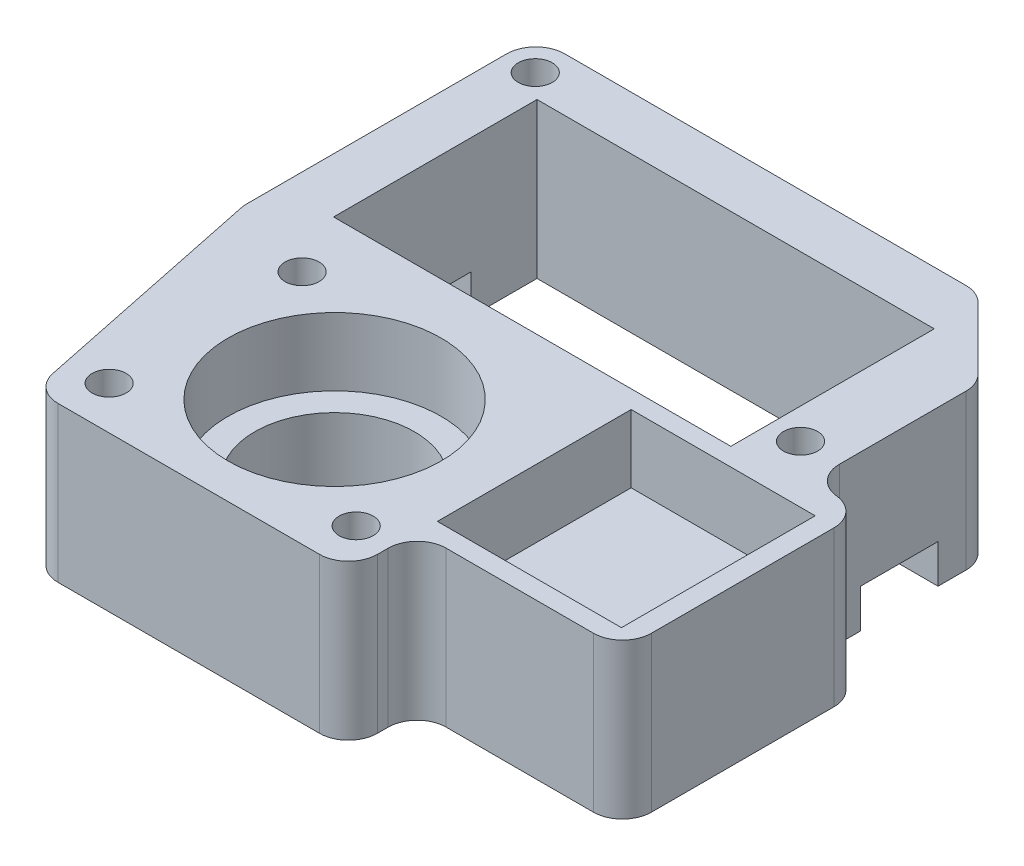
from build123d import *

# Parameters (mm, degrees)
ESBO_O1_R                = 8.25
ESBO_O1_R_2              = 1.759398981
ESBO_O1_W                = 41
ESBO_O1_H                = 21
RESSALTO_EXTRUS_O1_DEPTH = 16
ESBO_O2_R                = 11
ESBO_O2_W                = 19
ESBO_O2_H                = 20
CORTE_EXTRUS_O1_DEPTH    = 7
FILETE2_R                = 3
FILETE3_R                = 3
ESBO_O4_W                = 8
ESBO_O4_H                = 4
CORTE_EXTRUS_O2_DEPTH    = 60


with BuildPart() as part:
    # Esboço1 → Ressalto-extrusão1 (new body)
    with BuildSketch(Plane(origin=(0, 0, 0), x_dir=(1, 0, 0), z_dir=(0, 1, 0))):
        Polygon((-30, -1.447454982), (-30, 28.699395637), (15.649759457, 28.699395637), (23.854058099, 20.495096994), (23.854058099, 3.185553214), (29.26109124, 3.185553214), (29.26109124, -21.609914281), (8.073270411, -21.609914281), (8.073270411, -28.699395637), (-24.350240543, -28.699395637), align=None)
        with Locations((-7.979986437, -14.080173672)):
            Circle(ESBO_O1_R, mode=Mode.SUBTRACT)
        with Locations((-26.846540224, 25.498704653)):
            Circle(ESBO_O1_R_2, mode=Mode.SUBTRACT)
        with Locations((19.799323859, 6.233376584)):
            Circle(ESBO_O1_R_2, mode=Mode.SUBTRACT)
        with Locations((-21.074944534, -24.259345494)):
            Circle(ESBO_O1_R_2, mode=Mode.SUBTRACT)
        with Locations((4.428183177, -24.259345494)):
            Circle(ESBO_O1_R_2, mode=Mode.SUBTRACT)
        with Locations((-21.074944534, -4.342364945)):
            Circle(ESBO_O1_R_2, mode=Mode.SUBTRACT)
        with Locations((-3.850240543, 12.685553214)):
            Rectangle(ESBO_O1_W, ESBO_O1_H, mode=Mode.SUBTRACT)
    extrude(amount=RESSALTO_EXTRUS_O1_DEPTH)

    # Esboço2 → Corte-extrusão1 (cut)
    with BuildSketch(Plane(origin=(0, 16, 0), x_dir=(1, 0, 0), z_dir=(0, 1, 0))):
        with Locations((-7.979986437, -14.080173672)):
            Circle(ESBO_O2_R)
        with Locations((17.716848977, -9.668999278)):
            Rectangle(ESBO_O2_W, ESBO_O2_H)
    extrude(amount=-CORTE_EXTRUS_O1_DEPTH, mode=Mode.SUBTRACT)

    # Filete2
    filete2_edges = [part.edges().sort_by_distance(p)[0] for p in [
        (-30, 8, 1.447454982),
        (-30, 8, -28.699395637),
        (15.649759457, 8, -28.699395637),
        (23.854058099, 8, -20.495096994),
        (23.854058099, 8, -3.185553214),
        (8.073270411, 8, 28.699395637),
        (-24.350240543, 8, 28.699395637),
    ]]
    fillet(filete2_edges, radius=FILETE2_R)

    # Filete3
    filete3_edges = [part.edges().sort_by_distance(p)[0] for p in [
        (29.26109124, 8, -3.185553214),
        (8.073270411, 8, 21.609914281),
        (29.26109124, 8, 21.609914281),
    ]]
    fillet(filete3_edges, radius=FILETE3_R)

    # Esboço4 → Corte-extrusão2 (cut)
    with BuildSketch(Plane.ZY.offset(30)):
        with Locations((-12.370867745, 2)):
            Rectangle(ESBO_O4_W, ESBO_O4_H)
    extrude(amount=-CORTE_EXTRUS_O2_DEPTH, mode=Mode.SUBTRACT)


solid = part.part
